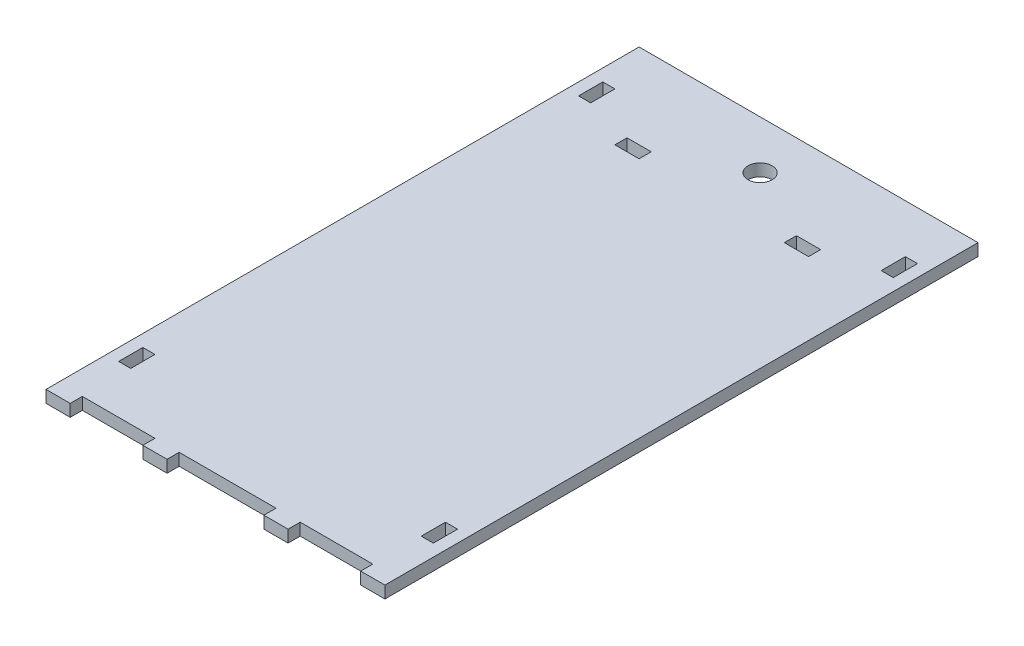
from build123d import *

# Parameters (mm, degrees)
SKETCH1_W           = 177.8
SKETCH1_H           = 304.8
SKETCH1_R           = 6.35
SKETCH1_W_2         = 12.7
SKETCH1_H_2         = 6.35
SKETCH1_W_3         = 6.35
SKETCH1_H_3         = 12.7
BOSS_EXTRUDE1_DEPTH = 6.35


with BuildPart() as part:
    # Sketch1 → Boss-Extrude1 (new body)
    with BuildSketch(Plane(origin=(0, 0, 0), x_dir=(1, 0, 0), z_dir=(0, 1, 0))):
        with Locations((88.9, 152.4)):
            Rectangle(SKETCH1_W, SKETCH1_H)
        with Locations((88.9, 279.4)):
            Circle(SKETCH1_R, mode=Mode.SUBTRACT)
        with Locations((44.45, 257.175)):
            Rectangle(SKETCH1_W_2, SKETCH1_H_2, mode=Mode.SUBTRACT)
        with Locations((168.275, 31.75)):
            Rectangle(SKETCH1_W_3, SKETCH1_H_3, mode=Mode.SUBTRACT)
        with Locations((9.525, 31.75)):
            Rectangle(SKETCH1_W_3, SKETCH1_H_3, mode=Mode.SUBTRACT)
        with Locations((9.525, 273.05)):
            Rectangle(SKETCH1_W_3, SKETCH1_H_3, mode=Mode.SUBTRACT)
        with Locations((168.275, 273.05)):
            Rectangle(SKETCH1_W_3, SKETCH1_H_3, mode=Mode.SUBTRACT)
        with Locations((133.35, 257.175)):
            Rectangle(SKETCH1_W_2, SKETCH1_H_2, mode=Mode.SUBTRACT)
        with Locations((6.35, -3.175)):
            Rectangle(SKETCH1_W_2, SKETCH1_H_2)
        with Locations((57.15, -3.175)):
            Rectangle(SKETCH1_W_2, SKETCH1_H_2)
        with Locations((120.65, -3.175)):
            Rectangle(SKETCH1_W_2, SKETCH1_H_2)
        with Locations((171.45, -3.175)):
            Rectangle(SKETCH1_W_2, SKETCH1_H_2)
    extrude(amount=BOSS_EXTRUDE1_DEPTH)


solid = part.part
